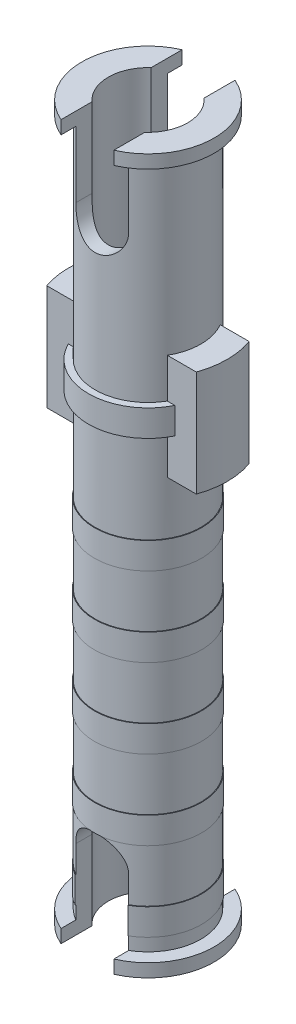
from build123d import *

# Parameters (mm, degrees)
SKETCH3_W               = 6
SKETCH3_H               = 4
BOSS_EXTRUDE4_DEPTH     = 1
SKETCH7_W               = 2.025
SKETCH7_H               = 1
LPATTERN1_COUNT         = 5
LPATTERN1_PITCH         = 3
CUT_EXTRUDE2_DEPTH      = 15.053469323
CUT_EXTRUDE2_DEPTH_BACK = 15.053469323
CUT_EXTRUDE3_REACH      = 29.263
SKETCH6_R               = 1.5
SKETCH8_OUTSIDE_W       = 13.608
SKETCH8_OUTSIDE_H       = 12.19
SKETCH8_OUTSIDE_R       = 3
CUT_EXTRUDE4_DEPTH      = 15.017845865
CUT_EXTRUDE4_DEPTH_BACK = 15.017845865


with BuildPart() as part:
    # Sketch1 → Revolve5 (revolve)
    with BuildSketch(Plane.XY):
        Polygon((0, 13.5), (-2.5, 13.5), (-2.5, 13), (-2, 13), (-2, 5), (-2.25, 5), (-2.25, 4), (-2, 4), (-2, -13), (-2.5, -13), (-2.5, -13.5), (0, -13.5), align=None)
    revolve(axis=Axis((0, 13.5, 0), (0, -1, 0)))

    # Sketch3 → Boss-Extrude4 (add, symmetric)
    with BuildSketch(Plane.XY):
        with Locations((0, 4.5)):
            Rectangle(SKETCH3_W, SKETCH3_H)
    extrude(amount=BOSS_EXTRUDE4_DEPTH, both=True)

    # Sketch7 → Revolve7 (revolve)
    with BuildSketch(Plane.XY, mode=Mode.PRIVATE) as revolve7_sk:
        with Locations((-1.0125, -0.004180602)):
            Rectangle(SKETCH7_W, SKETCH7_H)
    revolve7 = revolve(revolve7_sk.sketch.rotate(Axis((0, 5, 0), (0, -1, 0)), 330), axis=Axis((0, 5, 0), (0, -1, 0)))

    # LPattern1: Revolve7 ×5
    with Locations(*[(0, -i * LPATTERN1_PITCH, 0) for i in range(1, LPATTERN1_COUNT)]):
        add(revolve7)

    # Sketch5 → Cut-Extrude2 (cut, two sides)
    with BuildSketch(Plane.XY) as cut_extrude2_sk:
        with BuildLine():
            Line((-1, 13.5), (-1, 10.5))
            ThreePointArc((-1, 10.5), (0, 9.5), (1, 10.5))
            Line((1, 10.5), (1, 13.5))
            Line((1, 13.5), (-1, 13.5))
        make_face()
        with BuildLine():
            Line((-1, -13.5), (-1, -10.5))
            ThreePointArc((-1, -10.5), (0, -9.5), (1, -10.5))
            Line((1, -10.5), (1, -13.5))
            Line((1, -13.5), (-1, -13.5))
        make_face()
    extrude(amount=CUT_EXTRUDE2_DEPTH, mode=Mode.SUBTRACT)
    extrude(cut_extrude2_sk.sketch, amount=-CUT_EXTRUDE2_DEPTH_BACK, mode=Mode.SUBTRACT)

    # Cut-Extrude3: up to this face of the body (flat: up to its plane)
    cut_extrude3_end = Plane(part.part.faces().sort_by_distance((-1.618726141, -13.5, 0))[0])
    # Sketch6 → Cut-Extrude3 (cut, up to the picked face)
    with BuildSketch(Plane(origin=(0, 13.5, 0), x_dir=(1, 0, 0), z_dir=(0, 1, 0)), mode=Mode.PRIVATE) as cut_extrude3_sk1:
        with Locations(Location((0, 0, 0), (0, 0, 228.189685104))):
            Circle(SKETCH6_R)
    cut_extrude3_tool1 = split(extrude(cut_extrude3_sk1.sketch, amount=-CUT_EXTRUDE3_REACH, mode=Mode.PRIVATE), bisect_by=cut_extrude3_end, keep=Keep.BOTH, mode=Mode.PRIVATE)
    add(cut_extrude3_tool1.solids().sort_by(Axis((0, 13.5, 0), (0, -1, 0)))[0], mode=Mode.SUBTRACT)

    # Sketch8 outside → Cut-Extrude4 (cut, two sides)
    with BuildSketch(Plane(origin=(0, 0, 0), x_dir=(1, 0, 0), z_dir=(0, 1, 0))) as cut_extrude4_sk:
        Rectangle(SKETCH8_OUTSIDE_W, SKETCH8_OUTSIDE_H)
        Circle(SKETCH8_OUTSIDE_R, mode=Mode.SUBTRACT)
    extrude(amount=CUT_EXTRUDE4_DEPTH, mode=Mode.SUBTRACT)
    extrude(cut_extrude4_sk.sketch, amount=-CUT_EXTRUDE4_DEPTH_BACK, mode=Mode.SUBTRACT)


solid = part.part
